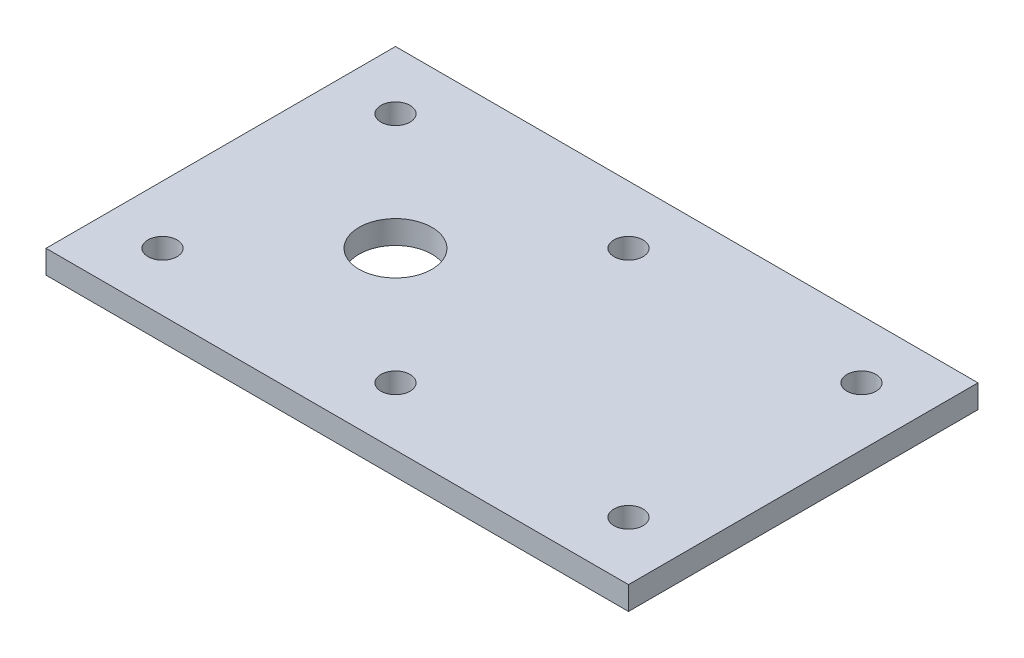
from build123d import *

# Parameters (mm, degrees)
SKETCH1_W            = 200
SKETCH1_H            = 120
BOSS_EXTRUDE3_DEPTH  = 8
SKETCH2_R            = 5
CUT_EXTRUDE1_DEPTH   = 9
LPATTERN5_COUNT      = 2
LPATTERN5_PITCH      = 80
LPATTERN5_COUNT_DIR2 = 3
LPATTERN5_PITCH_DIR2 = 80
SKETCH3_R            = 12.5
CUT_EXTRUDE2_DEPTH   = 10


with BuildPart() as part:
    # Sketch1 → Boss-Extrude3 (new body)
    with BuildSketch(Plane(origin=(0, 0, 0), x_dir=(1, 0, 0), z_dir=(0, 1, 0))):
        with Locations((40, 0)):
            Rectangle(SKETCH1_W, SKETCH1_H)
    extrude(amount=BOSS_EXTRUDE3_DEPTH)

    # Sketch2 → Cut-Extrude1 (cut, through all)
    with BuildSketch(Plane(origin=(0, 8, 0), x_dir=(1, 0, 0), z_dir=(0, 1, 0))):
        with Locations((-40, 40)):
            Circle(SKETCH2_R)
    cut_extrude1 = extrude(amount=-CUT_EXTRUDE1_DEPTH, mode=Mode.SUBTRACT)

    # LPattern5: Cut-Extrude1 2 × 3
    with Locations(*[(j * LPATTERN5_PITCH_DIR2, 0, i * LPATTERN5_PITCH) for i in range(LPATTERN5_COUNT) for j in range(LPATTERN5_COUNT_DIR2) if (i, j) != (0, 0)]):
        add(cut_extrude1, mode=Mode.SUBTRACT)

    # Sketch3 → Cut-Extrude2 (cut)
    with BuildSketch(Plane(origin=(0, 8, 0), x_dir=(1, 0, 0), z_dir=(0, 1, 0))):
        Circle(SKETCH3_R)
    extrude(amount=-CUT_EXTRUDE2_DEPTH, mode=Mode.SUBTRACT)


solid = part.part
